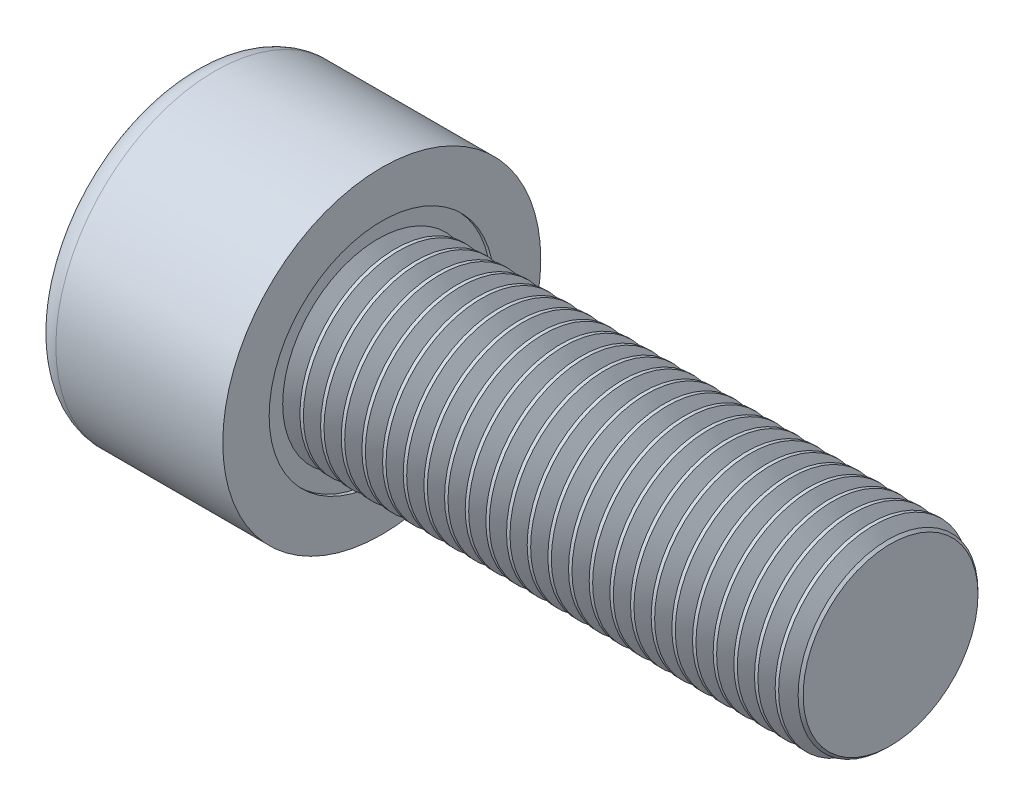
from build123d import *

# Parameters (mm, degrees)
SKETCH1_R           = 5
BASEHEAD_DEPTH      = 6
SKETCH2_R           = 3
BASEBODY_DEPTH      = 16
HEXAGONSOCKET_DEPTH = 3
TOPFILLET_R         = 0.75
CHAMFER1_SIZE       = 0.25
LPATTERN10_COUNT    = 25
LPATTERN10_PITCH    = 0.6498


with BuildPart() as part:
    # Sketch1 → BaseHead (new body)
    with BuildSketch(Plane(origin=(0, 0, 0), x_dir=(0, 0, -1), z_dir=(1, 0, 0))):
        Circle(SKETCH1_R)
    extrude(amount=BASEHEAD_DEPTH)

    # Sketch2 → BaseBody (add)
    with BuildSketch(Plane(origin=(6, 0, 0), x_dir=(0, 0, -1), z_dir=(1, 0, 0))):
        Circle(SKETCH2_R)
    extrude(amount=BASEBODY_DEPTH)

    # Sketch3 → HexagonSocket (cut)
    with BuildSketch(Plane(origin=(0, 0, 0), x_dir=(0, 0, -1), z_dir=(1, 0, 0))):
        Polygon((2.886751346, 0), (1.443375673, 2.5), (-1.443375673, 2.5), (-2.886751346, 0), (-1.443375673, -2.5), (1.443375673, -2.5), align=None)
    extrude(amount=HEXAGONSOCKET_DEPTH, mode=Mode.SUBTRACT)

    # Sketch4 → Cut-Revolve1 (revolve, cut)
    with BuildSketch(Plane(origin=(-4.19613823, 0.75, 0), x_dir=(-1, 0, 0), z_dir=(0, 0, 1))):
        Polygon((-7.19613823, 3.25), (-8.639513903, 0.75), (-7.19613823, 0.75), align=None)
    revolve(axis=Axis((0.838992387, 0, 0), (-1, 0, 0)), mode=Mode.SUBTRACT)

    # TopFillet
    topfillet_edges = [part.edges().sort_by_distance(p)[0] for p in [
        (0, 0, 5),
    ]]
    fillet(topfillet_edges, radius=TOPFILLET_R)

    # Chamfer1
    chamfer1_edges = [part.edges().sort_by_distance(p)[0] for p in [
        (22, 0, 3),
    ]]
    chamfer(chamfer1_edges, length=CHAMFER1_SIZE)

    # Sketch5 → Cut-Revolve10 (revolve, cut)
    with BuildSketch(Plane.XY):
        Polygon((21.75, 2.531047244), (22.02075, 3), (22.02075, 3.5415), (21.47925, 3.5415), (21.47925, 3), align=None)
    cut_revolve10 = revolve(axis=Axis((0, 0, 0), (1, 0, 0)), mode=Mode.SUBTRACT)

    # LPattern10: Cut-Revolve10 ×25
    with Locations(*[(-i * LPATTERN10_PITCH, 0, 0) for i in range(1, LPATTERN10_COUNT)]):
        add(cut_revolve10, mode=Mode.SUBTRACT)


solid = part.part
